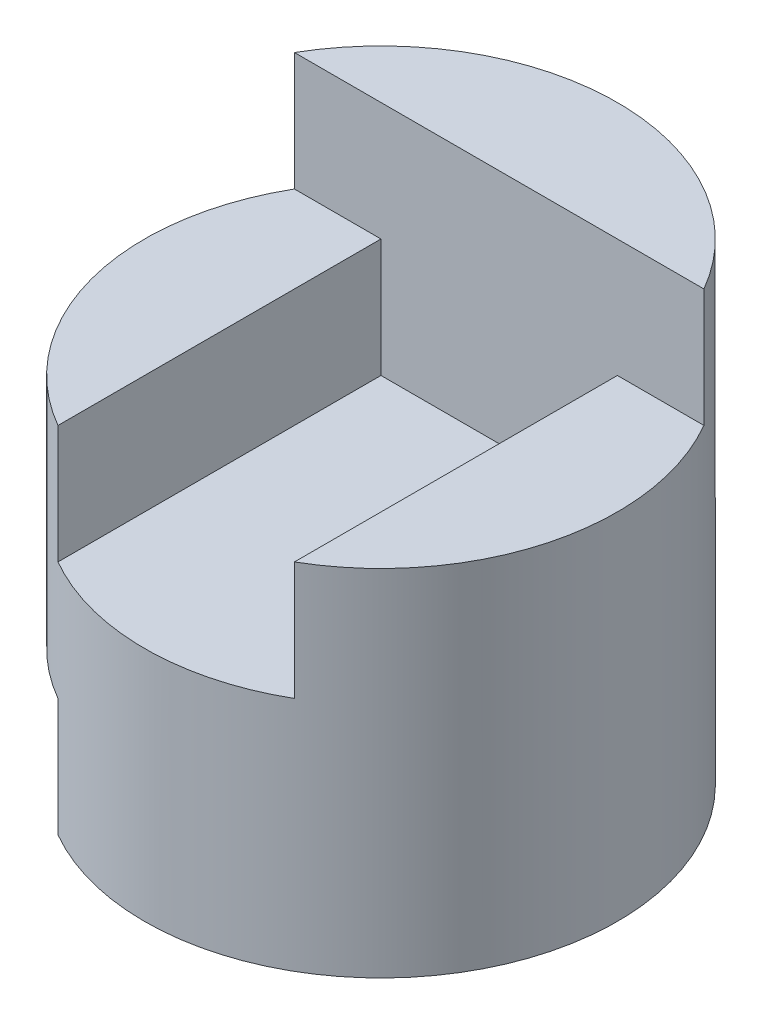
from build123d import *

# Parameters (mm, degrees)
SKETCH1_R               = 2
BOSS_EXTRUDE1_DEPTH     = 4
CUT_EXTRUDE1_DEPTH      = 3
CUT_EXTRUDE1_DEPTH_BACK = 1
CUT_EXTRUDE9_DEPTH      = 1


with BuildPart() as part:
    # Sketch1 → Boss-Extrude1 (new body)
    with BuildSketch(Plane(origin=(0, 0, 0), x_dir=(1, 0, 0), z_dir=(0, 1, 0))):
        Circle(SKETCH1_R)
    extrude(amount=BOSS_EXTRUDE1_DEPTH)

    # Sketch2 → Cut-Extrude1 (cut, two sides)
    with BuildSketch(Plane.XY) as cut_extrude1_sk:
        Polygon((-2, 4), (2, 4), (2, 3), (1, 3), (1, 2), (-1, 2), (-1, 3), (-2, 3), align=None)
    extrude(amount=CUT_EXTRUDE1_DEPTH, mode=Mode.SUBTRACT)
    extrude(cut_extrude1_sk.sketch, amount=-CUT_EXTRUDE1_DEPTH_BACK, mode=Mode.SUBTRACT)

    # Sketch4 → Cut-Extrude9 (cut)
    with BuildSketch(Plane.XZ):
        with BuildLine():
            Line((-1, 1.732050808), (-1, -1))
            Line((-1, -1), (-1.732050808, -1))
            ThreePointArc((-1.732050808, -1), (-1.931851653, 0.51763809), (-1, 1.732050808))
        make_face()
    extrude(amount=-CUT_EXTRUDE9_DEPTH, mode=Mode.SUBTRACT)


solid = part.part
